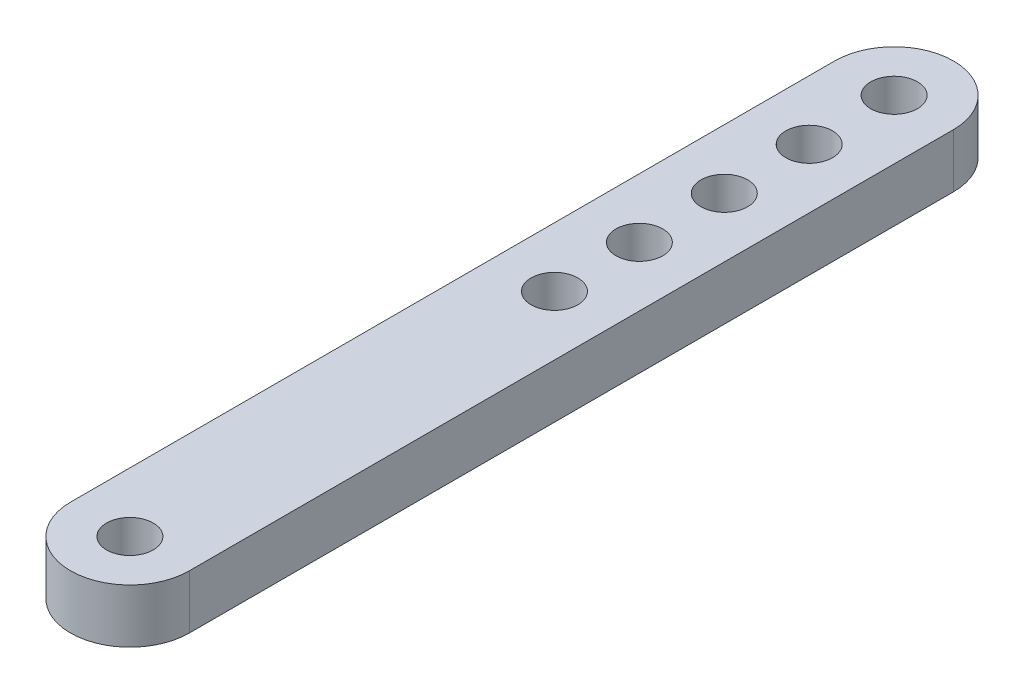
from build123d import *

# Parameters (mm, degrees)
SKETCH1_R           = 2.75
BOSS_EXTRUDE1_DEPTH = 6.35
SKETCH2_R           = 2.75
CUT_EXTRUDE1_DEPTH  = 6.35


with BuildPart() as part:
    # Sketch1 → Boss-Extrude1 (new body)
    with BuildSketch(Plane(origin=(0, 0, 0), x_dir=(1, 0, 0), z_dir=(0, 1, 0))):
        with BuildLine():
            Line((7, 90), (7, 0))
            ThreePointArc((7, 0), (0, -7), (-7, 0))
            Line((-7, 0), (-7, 90))
            ThreePointArc((-7, 90), (0, 97), (7, 90))
        make_face()
        with Locations((0, 90)):
            Circle(SKETCH1_R, mode=Mode.SUBTRACT)
        Circle(SKETCH1_R, mode=Mode.SUBTRACT)
    extrude(amount=BOSS_EXTRUDE1_DEPTH)

    # Sketch2 → Cut-Extrude1 (cut)
    with BuildSketch(Plane(origin=(0, 0, 0), x_dir=(1, 0, 0), z_dir=(0, 1, 0))):
        with Locations((0, 90)):
            Circle(SKETCH2_R)
        with Locations((0, 80)):
            Circle(SKETCH2_R)
        with Locations((0, 70)):
            Circle(SKETCH2_R)
        with Locations((0, 60)):
            Circle(SKETCH2_R)
        with Locations((0, 50)):
            Circle(SKETCH2_R)
    extrude(amount=CUT_EXTRUDE1_DEPTH, mode=Mode.SUBTRACT)


solid = part.part
